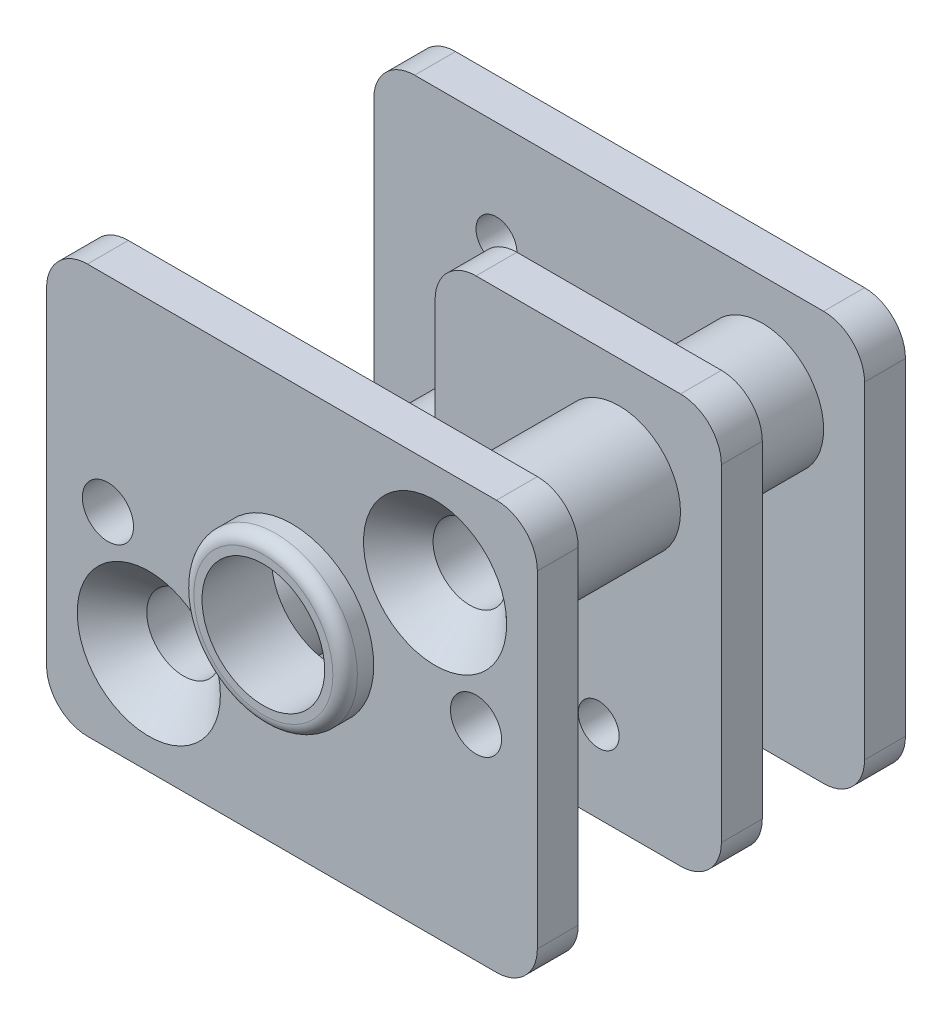
from build123d import *

# Parameters (mm, degrees)
SKETCH_1_W               = 12
SKETCH_1_H               = 10
SKETCH_1_R               = 1.5
EXTRUDE_1_DEPTH          = 1
SKETCH_4_R               = 1.5
SKETCH_4_R_2             = 0.9
EXTRUDE_2_DEPTH          = 3.5
SKETCH_5_R               = 0.5
EXTRUDE_3_DEPTH          = 1
SKETCH_6_R               = 1.5
SKETCH_6_R_2             = 0.9
EXTRUDE_4_DEPTH          = 2.5
SKETCH_7_W               = 12
SKETCH_7_H               = 10
SKETCH_7_R               = 0.532937176
SKETCH_7_R_2             = 0.5
EXTRUDE_5_DEPTH          = 1
FILLET_1_R               = 1
HOLE_WIZARD_1_AT_2_COUNT = 2
HOLE_WIZARD_1_AT_2_PITCH = 8.602325267
HOLE_WIZARD_M1_6_1_D     = 1.25
HOLE_WIZARD_M1_6_1_DEPTH = 1
SKETCH_12_R              = 2
SKETCH_12_R_2            = 1.5
EXTRUDE_6_DEPTH          = 0.7
FILLET_2_R               = 0.3


with BuildPart() as part:
    # 草图1 → 凸台-拉伸1 (new body)
    with BuildSketch(Plane.XY):
        Rectangle(SKETCH_1_W, SKETCH_1_H)
        Circle(SKETCH_1_R, mode=Mode.SUBTRACT)
    extrude(amount=EXTRUDE_1_DEPTH)

    # 草图4 → 凸台-拉伸2 (add)
    with BuildSketch(Plane(origin=(0, 0, 0), x_dir=(-1, 0, 0), z_dir=(0, 0, -1))):
        with Locations((-3.5, 2.5)):
            Circle(SKETCH_4_R)
        with Locations((-3.5, 2.5)):
            Circle(SKETCH_4_R_2, mode=Mode.SUBTRACT)
        with Locations((3.5, -2.5)):
            Circle(SKETCH_4_R)
        with Locations((3.5, -2.5)):
            Circle(SKETCH_4_R_2, mode=Mode.SUBTRACT)
    extrude(amount=EXTRUDE_2_DEPTH)

    # 草图5 → 凸台-拉伸3 (add)
    with BuildSketch(Plane(origin=(0, 0, -3.5), x_dir=(-1, 0, 0), z_dir=(0, 0, -1))):
        Polygon((-6, -5), (-6, 5), (1, 5), (1, 0), (6, 0), (6, -5), align=None)
        with Locations((-3, -3)):
            Circle(SKETCH_5_R, mode=Mode.SUBTRACT)
        Circle(SKETCH_5_R, mode=Mode.SUBTRACT)
    extrude(amount=EXTRUDE_3_DEPTH)

    # 草图6 → 凸台-拉伸4 (add)
    with BuildSketch(Plane(origin=(0, 0, -4.5), x_dir=(-1, 0, 0), z_dir=(0, 0, -1))):
        with Locations((3.5, -2.5)):
            Circle(SKETCH_6_R)
        with Locations((3.5, -2.5)):
            Circle(SKETCH_6_R_2, mode=Mode.SUBTRACT)
        with Locations((-3.5, 2.5)):
            Circle(SKETCH_6_R)
        with Locations((-3.5, 2.5)):
            Circle(SKETCH_6_R_2, mode=Mode.SUBTRACT)
    extrude(amount=EXTRUDE_4_DEPTH)

    # 草图7 → 凸台-拉伸5 (add)
    with BuildSketch(Plane(origin=(0, 0, -7), x_dir=(-1, 0, 0), z_dir=(0, 0, -1))):
        Rectangle(SKETCH_7_W, SKETCH_7_H)
        Circle(SKETCH_7_R, mode=Mode.SUBTRACT)
        with Locations((3, 2.5)):
            Circle(SKETCH_7_R_2, mode=Mode.SUBTRACT)
    extrude(amount=EXTRUDE_5_DEPTH)

    # 圆角1
    fillet_1_edges = [part.edges().sort_by_distance(p)[0] for p in [
        (6, -5, -4),
        (-6, -5, -4),
        (-6, 0, -4),
        (-1, 0, -4),
        (-1, 5, -4),
        (6, 5, -4),
        (-6, 5, -7.5),
        (6, 5, -7.5),
        (6, -5, -7.5),
        (-6, -5, -7.5),
        (6, -5, 0.5),
        (-6, -5, 0.5),
        (-6, 5, 0.5),
        (6, 5, 0.5),
    ]]
    fillet(fillet_1_edges, radius=FILLET_1_R)

    # 草图8 → 打孔尺寸根据开槽半沉头木螺钉的类型1 (revolve, cut)
    with BuildSketch(Plane(origin=(3.5, 2.5, 1), x_dir=(0, -1, 0), z_dir=(1, 0, 0))):
        Polygon((0, 0), (0, 1), (0.9, 1), (0.9, 0.85), (1.75, 0), align=None)
    hole_wizard_1 = revolve(axis=Axis((3.5, 2.5, 7.35), (0, 0, -1)), mode=Mode.SUBTRACT)

    # 打孔尺寸根据开槽半沉头木螺钉的类型1 at 2: 打孔尺寸根据开槽半沉头木螺钉的类型1 ×2
    with Locations(*[Vector(-0.813733471, -0.581238194, 0) * (i * HOLE_WIZARD_1_AT_2_PITCH) for i in range(1, HOLE_WIZARD_1_AT_2_COUNT)]):
        add(hole_wizard_1, mode=Mode.SUBTRACT)

    # M1.6 螺纹孔1
    with Locations(Plane.XY.offset(1)):
        with Locations((4.5, 0), (-4.5, 0)):
            Hole(HOLE_WIZARD_M1_6_1_D / 2, depth=HOLE_WIZARD_M1_6_1_DEPTH)

    # 草图12 → 凸台-拉伸6 (add)
    with BuildSketch(Plane.XY.offset(1)):
        Circle(SKETCH_12_R)
        Circle(SKETCH_12_R_2, mode=Mode.SUBTRACT)
    extrude(amount=EXTRUDE_6_DEPTH)

    # 圆角2
    fillet_2_edges = [part.edges().sort_by_distance(p)[0] for p in [
        (-2, 0, 1.7),
    ]]
    fillet(fillet_2_edges, radius=FILLET_2_R)


solid = part.part
